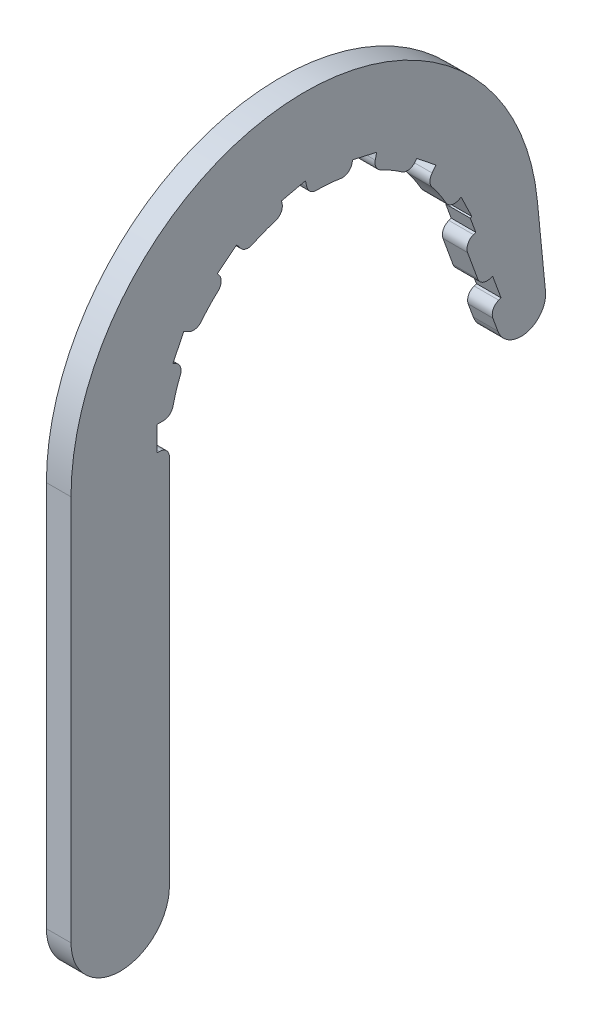
from build123d import *

# Parameters (mm, degrees)
BOSS_EXTRUDE1_DEPTH = 6.35
CUT_EXTRUDE1_START  = -7.35
CUT_EXTRUDE1_DEPTH  = 8.35
LPATTERN1_COUNT     = 2
LPATTERN1_PITCH     = 19.05
CUT_EXTRUDE2_START  = -7.35
CUT_EXTRUDE2_DEPTH  = 8.35
CIRPATTERN2_COUNT   = 8
CIRPATTERN2_ANGLE   = 180
FILLET1_R           = 2.54


with BuildPart() as part:
    # Sketch1 → Boss-Extrude1 (new body)
    with BuildSketch(Plane(origin=(0, 0, 0), x_dir=(0, 0, -1), z_dir=(1, 0, 0))):
        with BuildLine():
            Line((-63.5, -98.425), (-63.5, 1.27))
            ThreePointArc((-63.5, 1.27), (-6.13650031, 61.522262538), (56.859225559, 7.185858903))
            Line((56.859225559, 7.185858903), (58.947868709, -14.009723349))
            ThreePointArc((58.947868709, -14.009723349), (54.036813814, -20.824301776), (46.661428403, -16.804273249))
            Line((46.661428403, -16.804273249), (35.802288852, 13.030967461))
            ThreePointArc((35.802288852, 13.030967461), (-6.615995569, 37.52117539), (-38.1, 0))
            Line((-38.1, 0), (-38.1, -98.425))
            ThreePointArc((-38.1, -98.425), (-50.8, -111.125), (-63.5, -98.425))
        make_face()
    extrude(amount=BOSS_EXTRUDE1_DEPTH)

    # Sketch4 → Cut-Extrude1 (cut)
    with BuildSketch(Plane(origin=(6.35, 0, 0), x_dir=(0, 0, -1), z_dir=(1, 0, 0)).offset(CUT_EXTRUDE1_START)):
        Polygon((44.489600492, -10.837225107), (47.473124563, -9.751311152), (45.301296653, -3.78426301), (42.317772582, -4.870176965), align=None)
    cut_extrude1 = extrude(amount=CUT_EXTRUDE1_DEPTH, mode=Mode.SUBTRACT)

    # LPattern1: Cut-Extrude1 ×2
    with Locations(*[Vector(0, 0.939692621, 0.342020143) * (i * LPATTERN1_PITCH) for i in range(1, LPATTERN1_COUNT)]):
        add(cut_extrude1, mode=Mode.SUBTRACT)

    # Sketch5 → Cut-Extrude2 (cut)
    with BuildSketch(Plane(origin=(6.35, 0, 0), x_dir=(0, 0, -1), z_dir=(1, 0, 0)).offset(CUT_EXTRUDE2_START)):
        Polygon((-38.1, 0), (-41.275, 0), (-41.275, 6.35), (-38.1, 6.35), (-35.06174314, 6.35), (-35.06174314, 0), align=None)
    cut_extrude2 = extrude(amount=CUT_EXTRUDE2_DEPTH, mode=Mode.SUBTRACT)

    # CirPattern2: Cut-Extrude2 ×8 about axis, 1 skipped
    cirpattern2_axis = Axis((0, 0, 0), (-1, 0, 0))
    add([cut_extrude2.rotate(cirpattern2_axis, i * CIRPATTERN2_ANGLE / (CIRPATTERN2_COUNT - 1)) for i in range(1, CIRPATTERN2_COUNT) if i not in (7,)], mode=Mode.SUBTRACT)

    # Fillet1
    fillet1_edges = [part.edges().sort_by_distance(p)[0] for p in [
        (3.175, 16.53097046, 34.326913867),
        (3.175, 22.020909, 31.091631781),
        (3.175, 29.787779482, 23.754961451),
        (3.175, 33.330306905, 18.458077951),
        (3.175, 37.144753454, 8.478047584),
        (3.175, 38.038228757, 2.168675409),
        (3.175, 37.144753454, -8.478047584),
        (3.175, 0, 38.1),
        (3.175, 35.212212896, -14.550259894),
        (3.175, 29.787779482, -23.754961451),
        (3.175, 25.411986421, -28.387337778),
        (3.175, 16.53097046, -34.326913867),
        (3.175, -10.837225107, -44.489600492),
        (3.175, -4.870176965, -42.317772582),
        (3.175, 7.063919319, -37.974116762),
        (3.175, 6.35, 37.567106623),
    ]]
    fillet(fillet1_edges, radius=FILLET1_R)


solid = part.part
